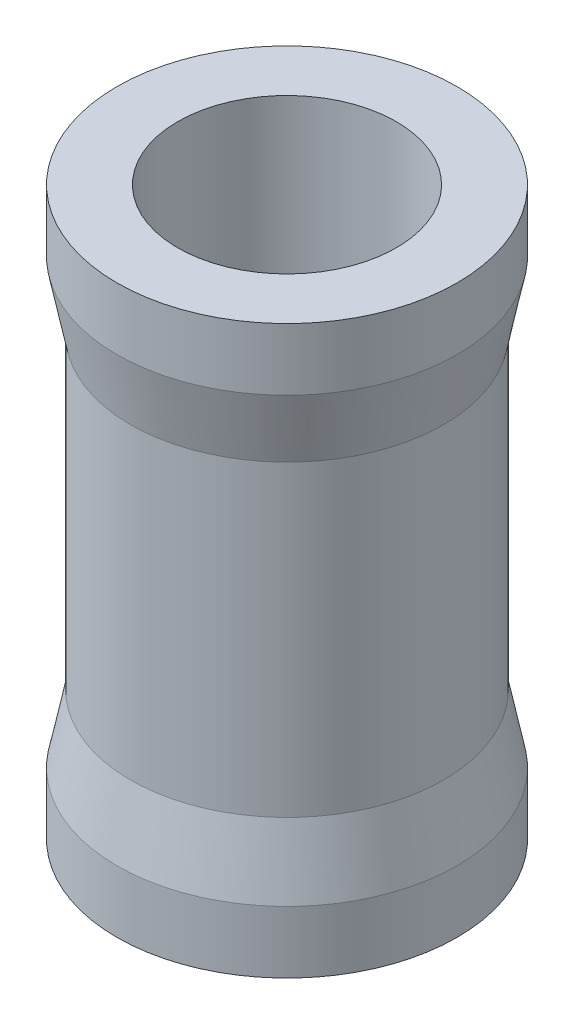
from build123d import *


with BuildPart() as part:
    # Sketch1 → Revolve1 (revolve)
    with BuildSketch(Plane.XY):
        Polygon((4.05, 10.5), (6.3, 10.5), (6.3, 8.2), (5.8, 5.7), (5.8, -5.7), (6.3, -8.2), (6.3, -10.5), (4.05, -10.5), align=None)
    revolve(axis=Axis((0, 10.5, 0), (0, -1, 0)))


solid = part.part
